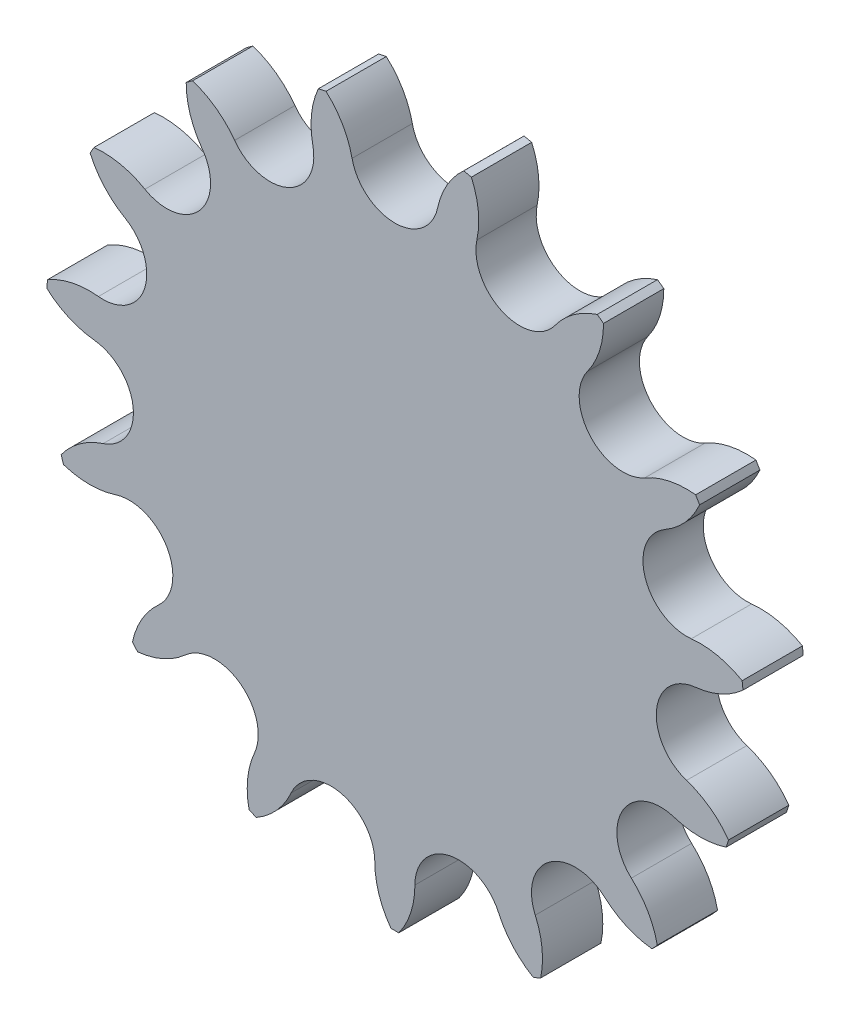
from build123d import *

# Parameters (mm, degrees)
EXTRUDE_1_DEPTH          = 6
PATTERN_CIRCULAR_1_COUNT = 15


with BuildPart() as part:
    # Эскиз2 → Бобышка-Вытянуть1 (new body)
    with BuildSketch(Plane.XY):
        with BuildLine():
            Line((0, 0), (0, 26.186813089))
            ThreePointArc((0, 26.186813089), (2.740690303, 27.157342427), (4.259832801, 29.636357676))
            ThreePointArc((4.259832801, 29.636357676), (5.200184386, 32.081950609), (6.852527049, 34.115408164))
            ThreePointArc((6.852527049, 34.115408164), (7.234664244, 34.036419236), (7.615891635, 33.953150012))
            ThreePointArc((7.615891635, 33.953150012), (8.298300069, 31.423425792), (8.162641728, 28.806790029))
            ThreePointArc((8.162641728, 28.806790029), (8.542141116, 25.924205989), (10.651136449, 23.922844148))
            Line((10.651136449, 23.922844148), (0, 0))
        make_face()
    extrude_1 = extrude(amount=EXTRUDE_1_DEPTH)

    # Круговой массив1: Бобышка-Вытянуть1 ×15 about axis
    pattern_circular_1_axis = Axis((0, 0, 0), (0, 0, 1))
    for i in range(1, PATTERN_CIRCULAR_1_COUNT):
        add(extrude_1.rotate(pattern_circular_1_axis, i * 360 / PATTERN_CIRCULAR_1_COUNT))


solid = part.part
